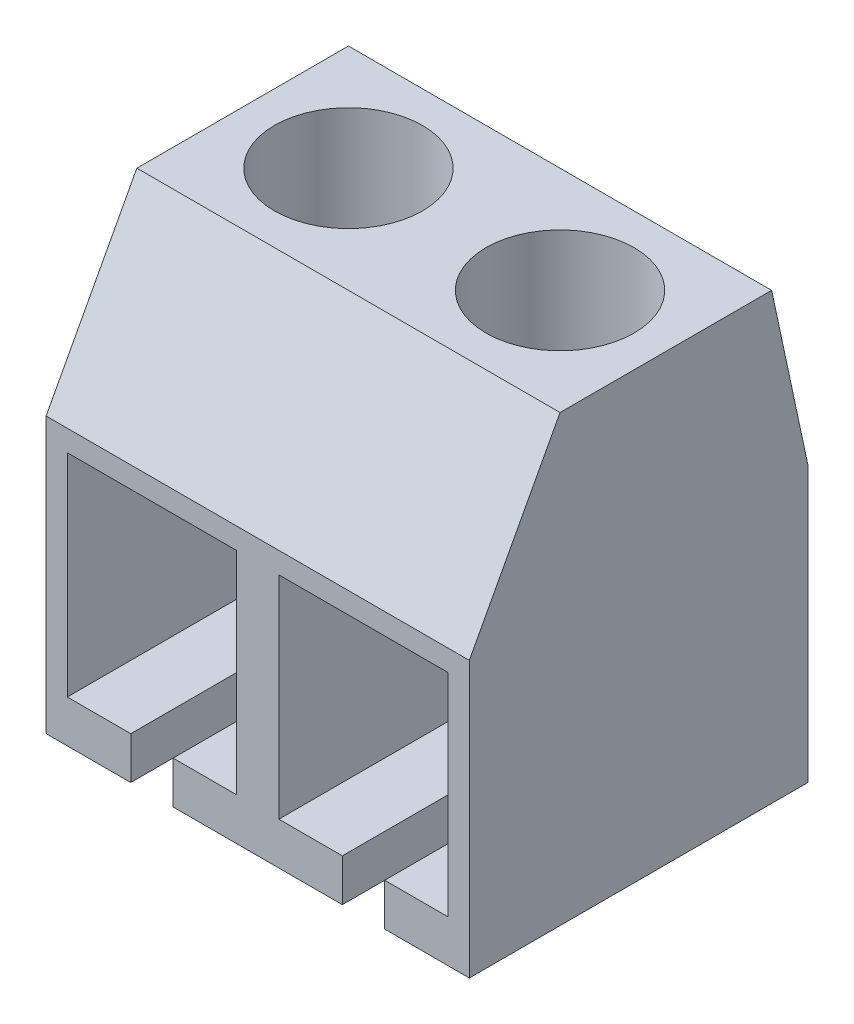
from build123d import *

# Parameters (mm, degrees)
Y_KSEKLIK_EKSTR_ZYON1_DEPTH      = 5
Y_KSEKLIK_EKSTR_ZYON1_DEPTH_BACK = 5
KES_EKSTR_ZYON1_DEPTH            = 10
IZIM3_R                          = 1.75
KES_EKSTR_ZYON2_DEPTH            = 7


with BuildPart() as part:
    # izim1 → Y_kseklik-Ekstr_zyon1 (new body, two sides)
    with BuildSketch(Plane(origin=(0, 0, 0), x_dir=(0, 0, -1), z_dir=(1, 0, 0))) as y_kseklik_ekstr_zyon1_sk:
        Polygon((-1.856187291, 5), (3.143812709, 5), (4, 1), (4, -5.5), (-4, -5.5), (-4, 1), align=None)
    extrude(amount=Y_KSEKLIK_EKSTR_ZYON1_DEPTH)
    extrude(y_kseklik_ekstr_zyon1_sk.sketch, amount=-Y_KSEKLIK_EKSTR_ZYON1_DEPTH_BACK)

    # izim2 → Kes-Ekstr_zyon1 (cut)
    with BuildSketch(Plane(origin=(0, 0, -4), x_dir=(-1, 0, 0), z_dir=(0, 0, -1))):
        Polygon((-3, -4.5), (-3, -5.5), (-2, -5.5), (-2, -4.5), (-0.5, -4.5), (-0.5, 0.5), (-4.5, 0.5), (-4.5, -4.5), align=None)
        Polygon((2, -4.5), (2, -5.5), (3, -5.5), (3, -4.5), (4.5, -4.5), (4.5, 0.5), (0.5, 0.5), (0.5, -4.5), align=None)
    extrude(amount=-KES_EKSTR_ZYON1_DEPTH, mode=Mode.SUBTRACT)

    # izim3 → Kes-Ekstr_zyon2 (cut)
    with BuildSketch(Plane(origin=(0, 5, 0), x_dir=(1, 0, 0), z_dir=(0, 1, 0))):
        with Locations((-2.5, 0.643812709)):
            Circle(IZIM3_R)
        with Locations((2.5, 0.643812709)):
            Circle(IZIM3_R)
    extrude(amount=-KES_EKSTR_ZYON2_DEPTH, mode=Mode.SUBTRACT)


solid = part.part
